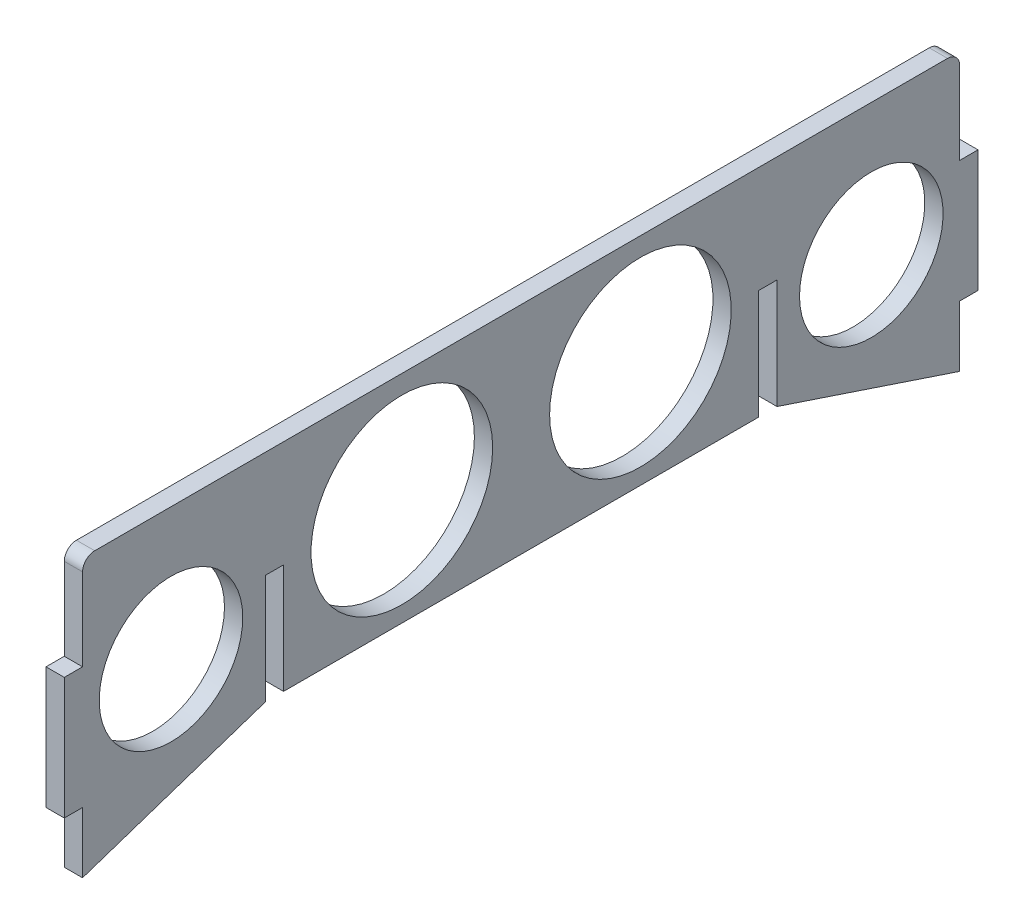
from build123d import *

# Parameters (mm, degrees)
SKETCH1_W           = 144
SKETCH1_H           = 35.5
BOSS_EXTRUDE1_DEPTH = 3
FILLET1_R           = 2
SKETCH2_W           = 3
SKETCH2_H           = 18
CUT_EXTRUDE1_DEPTH  = 3
BOSS_EXTRUDE2_DEPTH = 3
SKETCH4_W           = 3
SKETCH4_H           = 20
BOSS_EXTRUDE3_DEPTH = 3
SKETCH6_R           = 11.782762771
SKETCH6_R_2         = 14.90857156
CUT_EXTRUDE2_DEPTH  = 10


with BuildPart() as part:
    # Sketch1 → Boss-Extrude1 (new body)
    with BuildSketch(Plane(origin=(0, 0, 0), x_dir=(0, 0, -1), z_dir=(1, 0, 0))):
        Rectangle(SKETCH1_W, SKETCH1_H)
    extrude(amount=BOSS_EXTRUDE1_DEPTH)

    # Fillet1
    fillet1_edges = [part.edges().sort_by_distance(p)[0] for p in [
        (1.5, 17.75, 72),
        (1.5, 17.75, -72),
    ]]
    fillet(fillet1_edges, radius=FILLET1_R)

    # Sketch2 → Cut-Extrude1 (cut)
    with BuildSketch(Plane(origin=(3, 0, 0), x_dir=(0, 0, -1), z_dir=(1, 0, 0))):
        with Locations((-40.5, -8.75)):
            Rectangle(SKETCH2_W, SKETCH2_H)
        with Locations((40.5, -8.75)):
            Rectangle(SKETCH2_W, SKETCH2_H)
    extrude(amount=-CUT_EXTRUDE1_DEPTH, mode=Mode.SUBTRACT)

    # Sketch3 → Boss-Extrude2 (add)
    with BuildSketch(Plane(origin=(3, 0, 0), x_dir=(0, 0, -1), z_dir=(1, 0, 0))):
        Polygon((-72, -17.75), (-72, -27.75), (-42, -17.75), align=None)
    boss_extrude2 = extrude(amount=-BOSS_EXTRUDE2_DEPTH)

    # Mirror1: Boss-Extrude2 across plane
    add(boss_extrude2.mirror(Plane.XY))

    # Sketch4 → Boss-Extrude3 (add)
    with BuildSketch(Plane(origin=(3, 0, 0), x_dir=(0, 0, -1), z_dir=(1, 0, 0))):
        with Locations((-73.5, -7.75)):
            Rectangle(SKETCH4_W, SKETCH4_H)
        with Locations((73.5, -7.75)):
            Rectangle(SKETCH4_W, SKETCH4_H)
    extrude(amount=-BOSS_EXTRUDE3_DEPTH)

    # Sketch6 → Cut-Extrude2 (cut)
    with BuildSketch(Plane(origin=(3, 0, 0), x_dir=(0, 0, -1), z_dir=(1, 0, 0))):
        with Locations((-57.483097662, -3.908912232)):
            Circle(SKETCH6_R)
        with Locations((-19.582154149, -0.233669225)):
            Circle(SKETCH6_R_2)
        with Locations((57.483097662, -3.908912232)):
            Circle(SKETCH6_R)
        with Locations((19.582154149, -0.233669225)):
            Circle(SKETCH6_R_2)
    extrude(amount=-CUT_EXTRUDE2_DEPTH, mode=Mode.SUBTRACT)


solid = part.part
